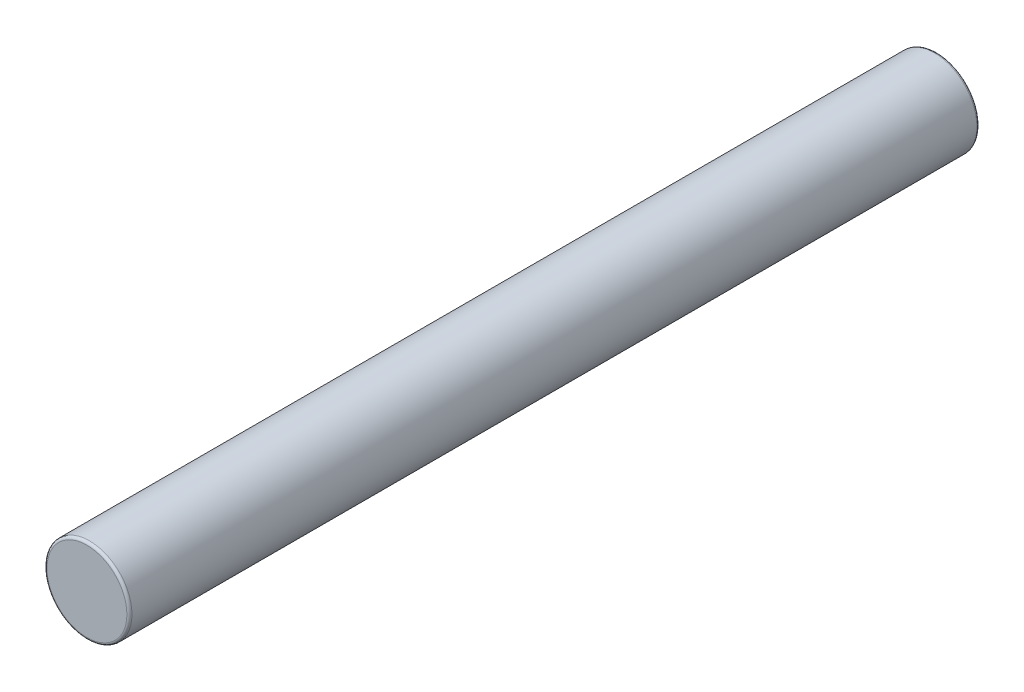
from build123d import *

# Parameters (mm, degrees)
SKETCH1_R           = 5
BOSS_EXTRUDE1_DEPTH = 50
FILLET1_R           = 0.3


with BuildPart() as part:
    # Sketch1 → Boss-Extrude1 (new body, symmetric)
    with BuildSketch(Plane.XY):
        Circle(SKETCH1_R)
    extrude(amount=BOSS_EXTRUDE1_DEPTH, both=True)

    # Fillet1
    fillet1_edges = [part.edges().sort_by_distance(p)[0] for p in [
        (-5, 0, -50),
        (-5, 0, 50),
    ]]
    fillet(fillet1_edges, radius=FILLET1_R)


solid = part.part
